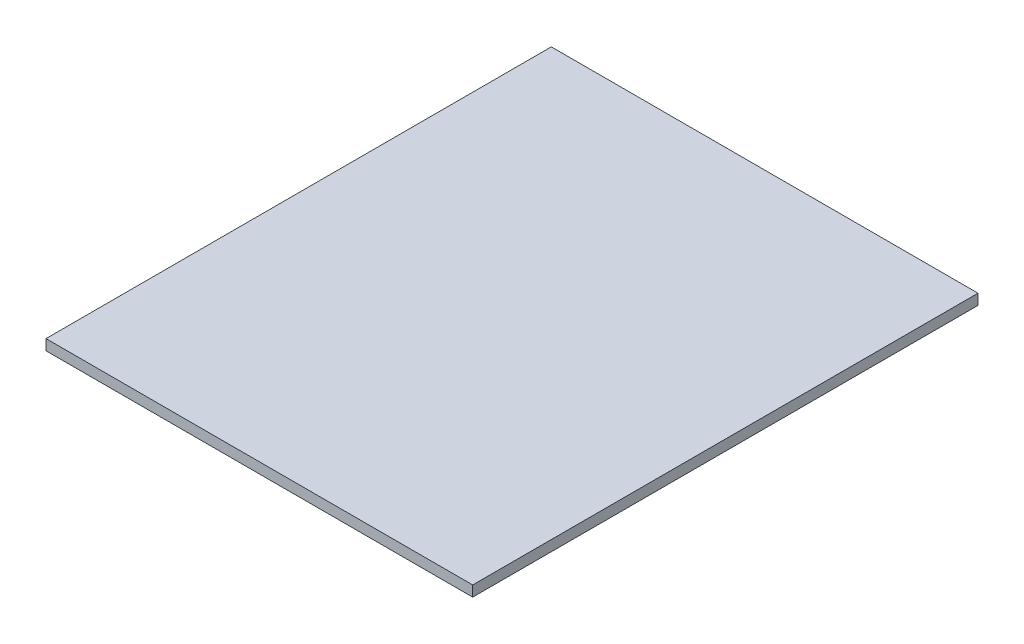
from build123d import *

# Parameters (mm, degrees)
SKETCH1_W           = 120.904
SKETCH1_H           = 143.1798
BOSS_EXTRUDE1_DEPTH = 1.4986


with BuildPart() as part:
    # Sketch1 → Boss-Extrude1 (new body, symmetric)
    with BuildSketch(Plane(origin=(0, 0, 0), x_dir=(1, 0, 0), z_dir=(0, 1, 0))):
        Rectangle(SKETCH1_W, SKETCH1_H)
    extrude(amount=BOSS_EXTRUDE1_DEPTH, both=True)


solid = part.part
